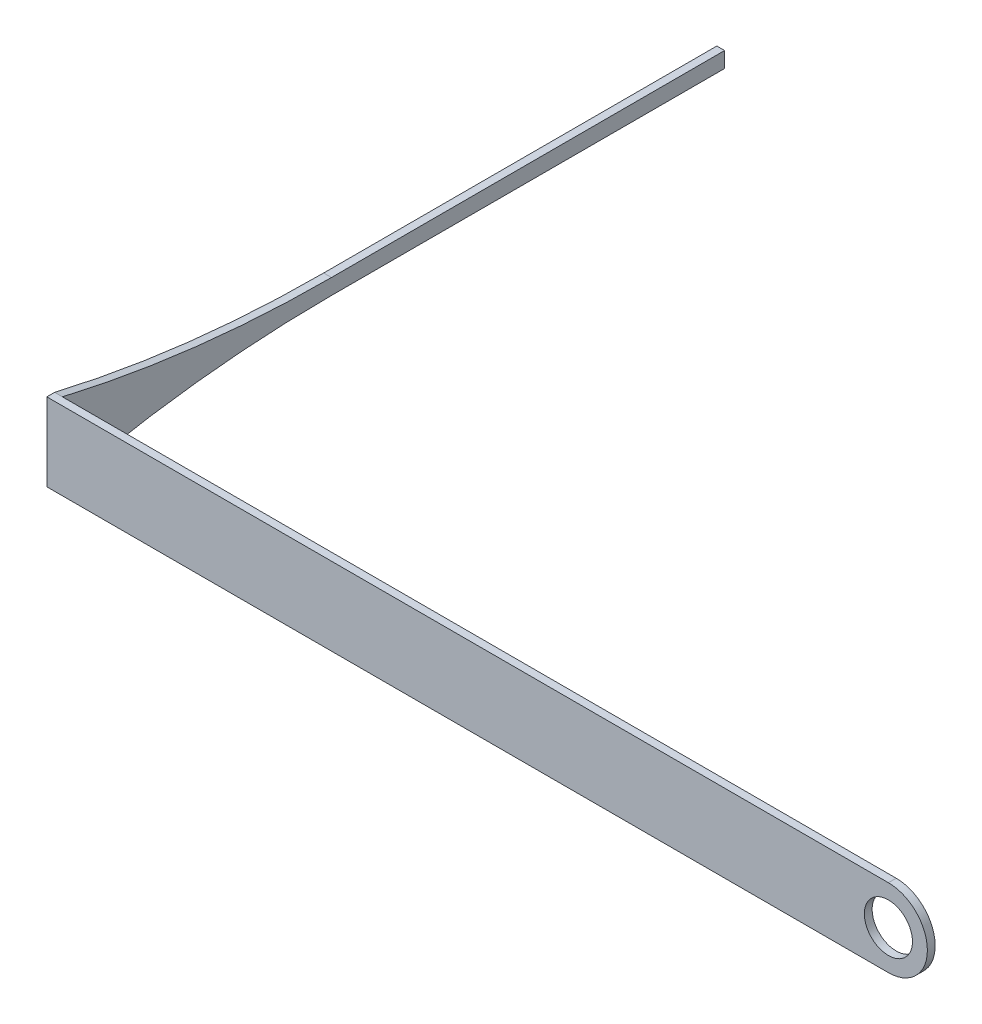
from build123d import *

# Parameters (mm, degrees)
BOSS_EXTRUDE1_DEPTH     = 5
SKETCH2_R               = 5
SKETCH2_R_2             = 3.088913235
BOSS_EXTRUDE2_DEPTH     = 1
SKETCH3_R               = 3.088913235
CUT_EXTRUDE1_DEPTH      = 1
CUT_EXTRUDE2_DEPTH      = 1
CUT_EXTRUDE2_DEPTH_BACK = 10


with BuildPart() as part:
    # Sketch1 → Boss-Extrude1 (new body, symmetric)
    with BuildSketch(Plane(origin=(0, 0, 0), x_dir=(1, 0, 0), z_dir=(0, 1, 0))):
        Polygon((0, 0), (-107, 0), (-107, 84.981911775), (-108, 84.981911775), (-108, -1), (0, -1), align=None)
    extrude(amount=BOSS_EXTRUDE1_DEPTH, both=True)

    # Sketch2 → Boss-Extrude2 (add)
    with BuildSketch(Plane.XY.offset(1)):
        Circle(SKETCH2_R)
        Circle(SKETCH2_R_2, mode=Mode.SUBTRACT)
    extrude(amount=-BOSS_EXTRUDE2_DEPTH)

    # Sketch3 → Cut-Extrude1 (cut)
    with BuildSketch(Plane.XY.offset(1)):
        Circle(SKETCH3_R)
    extrude(amount=-CUT_EXTRUDE1_DEPTH, mode=Mode.SUBTRACT)

    # Sketch4 → Cut-Extrude2 (cut, two sides)
    with BuildSketch(Plane.ZY.offset(108)) as cut_extrude2_sk:
        with BuildLine():
            Line((-84.981911775, 5), (-84.981911775, 1))
            Line((-84.981911775, 1), (-34.527427825, 1))
            ThreePointArc((-34.527427825, 1), (-17.14825011, 2.003332972), (0, 5))
            Line((0, 5), (-84.981911775, 5))
        make_face()
        with BuildLine():
            Line((-34.527427825, -1), (-84.981911775, -1))
            Line((-84.981911775, -1), (-84.981911775, -5))
            Line((-84.981911775, -5), (0, -5))
            ThreePointArc((0, -5), (-17.14825011, -2.003332972), (-34.527427825, -1))
        make_face()
    extrude(amount=CUT_EXTRUDE2_DEPTH, mode=Mode.SUBTRACT)
    extrude(cut_extrude2_sk.sketch, amount=-CUT_EXTRUDE2_DEPTH_BACK, mode=Mode.SUBTRACT)


solid = part.part
